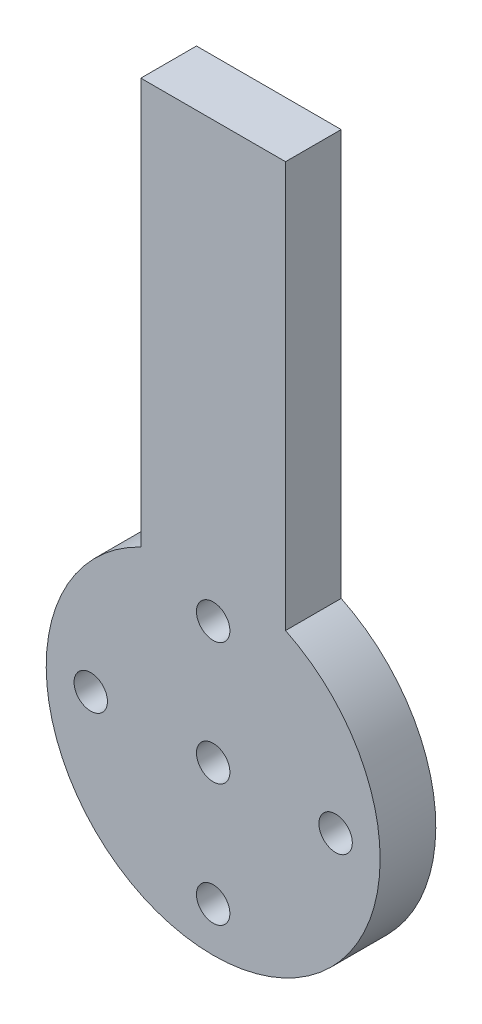
from build123d import *

# Parameters (mm, degrees)
SKETCH_1_R      = 1.5
EXTRUDE_1_DEPTH = 5


with BuildPart() as part:
    # 草图1 → 凸台-拉伸1 (new body)
    with BuildSketch(Plane.XY):
        with BuildLine():
            Line((2468.807860146, 4706.466341516), (2468.807860146, 4742.947835682))
            Line((2468.807860146, 4742.947835682), (2481.807860146, 4742.947835682))
            Line((2481.807860146, 4742.947835682), (2481.807860146, 4706.466341516))
            ThreePointArc((2481.807860146, 4706.466341516), (2475.307860146, 4677.947835682), (2468.807860146, 4706.466341516))
        make_face()
        with Locations((2475.307860146, 4692.947835682)):
            Circle(SKETCH_1_R, mode=Mode.SUBTRACT)
        with Locations((2464.307860146, 4692.947835682)):
            Circle(SKETCH_1_R, mode=Mode.SUBTRACT)
        with Locations((2486.307860146, 4692.947835682)):
            Circle(SKETCH_1_R, mode=Mode.SUBTRACT)
        with Locations((2475.307860146, 4703.947835682)):
            Circle(SKETCH_1_R, mode=Mode.SUBTRACT)
        with Locations((2475.307860146, 4681.947835682)):
            Circle(SKETCH_1_R, mode=Mode.SUBTRACT)
    extrude(amount=EXTRUDE_1_DEPTH)


solid = part.part
